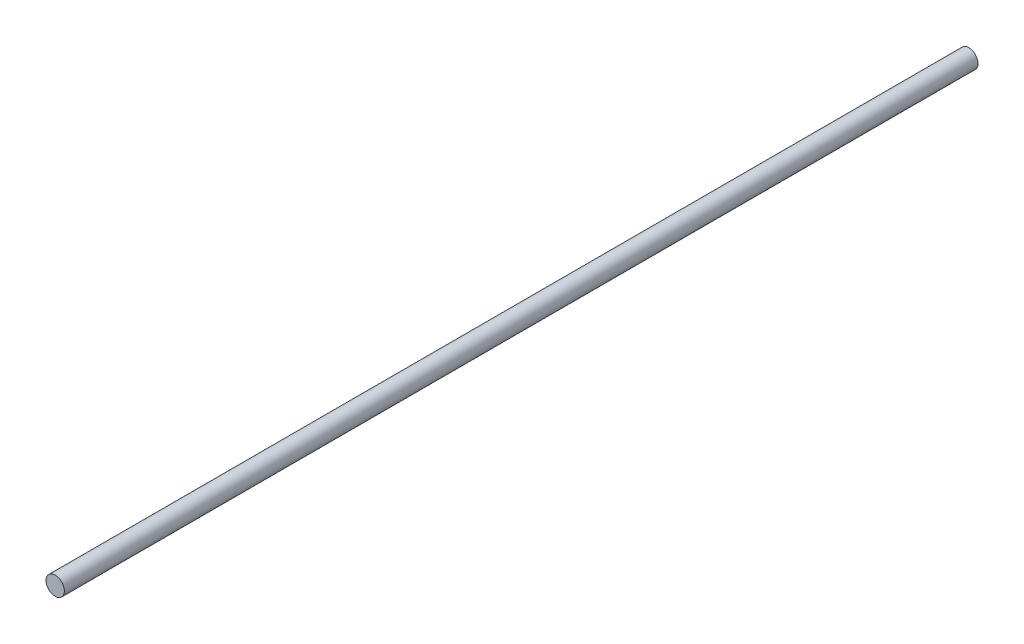
from build123d import *

# Parameters (mm, degrees)
SKETCH2_W = 397.80319436
SKETCH2_H = 4


with BuildPart() as part:
    # Sketch2 → Revolve1 (revolve)
    with BuildSketch(Plane(origin=(0, 0, 0), x_dir=(0, 0, -1), z_dir=(1, 0, 0))):
        with Locations((191.101596989, 2)):
            Rectangle(SKETCH2_W, SKETCH2_H)
    revolve(axis=Axis((0, 0, 7.800000191), (0, 0, -1)))


solid = part.part
